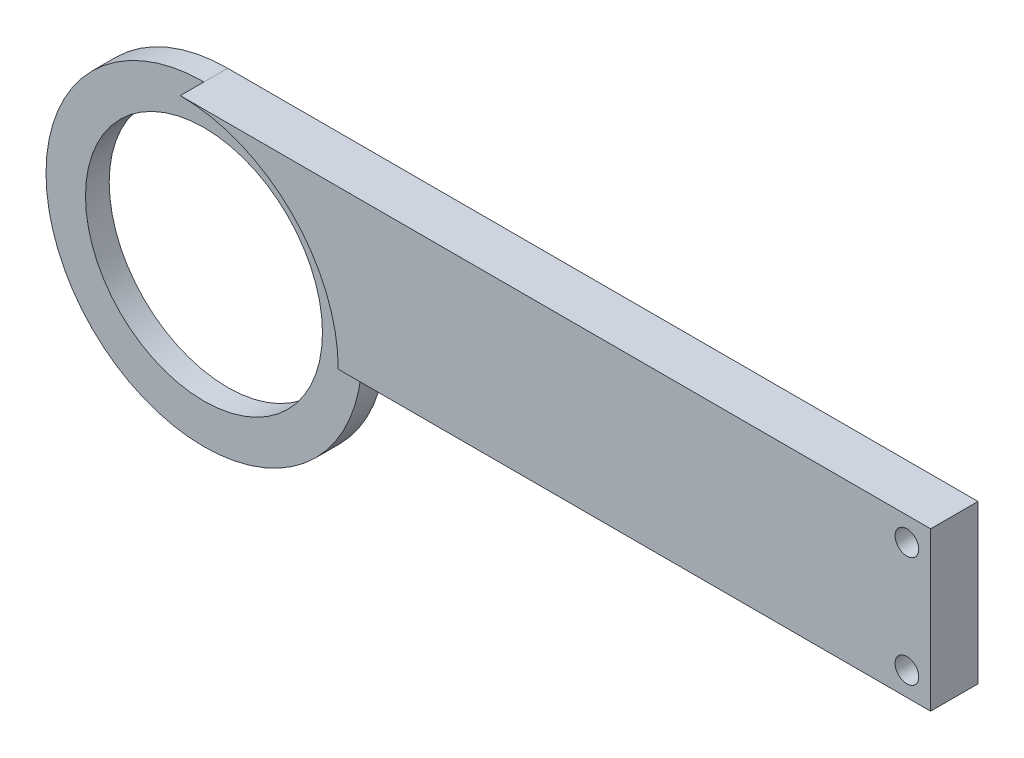
from build123d import *

# Parameters (mm, degrees)
BOSS_EXTRU_1_DEPTH      = 6
ESQUISSE2_R             = 20
ESQUISSE2_R_2           = 15
ENL_V_MAT_EXTRU_1_DEPTH = 3
ESQUISSE3_W             = 9.17
ESQUISSE3_H             = 20
BOSS_EXTRU_2_DEPTH      = 6
ESQUISSE4_R             = 1.5
ENL_V_MAT_EXTRU_2_DEPTH = 10


with BuildPart() as part:
    # Esquisse1 → Boss.-Extru.1 (new body)
    with BuildSketch(Plane.XY):
        with BuildLine():
            Line((42.613906887, 3.786407767), (42.613906887, 23.786407767))
            Line((42.613906887, 23.786407767), (-43.211335831, 23.786407767))
            ThreePointArc((-43.211335831, 23.786407767), (-29.069200208, 17.928543391), (-23.211335831, 3.786407767))
            Line((-23.211335831, 3.786407767), (42.613906887, 3.786407767))
        make_face()
        with BuildLine():
            ThreePointArc((-23.211335831, 3.786407767), (-29.069200208, 17.928543391), (-43.211335831, 23.786407767))
            Line((-43.211335831, 23.786407767), (-43.211335831, 18.786407767))
            ThreePointArc((-43.211335831, 18.786407767), (-32.604734113, 14.393009485), (-28.211335831, 3.786407767))
            Line((-28.211335831, 3.786407767), (-23.211335831, 3.786407767))
        make_face()
        with BuildLine():
            Line((-43.211335831, 18.786407767), (-43.211335831, 23.786407767))
            ThreePointArc((-43.211335831, 23.786407767), (-57.353471455, -10.355727857), (-23.211335831, 3.786407767))
            Line((-23.211335831, 3.786407767), (-28.211335831, 3.786407767))
            ThreePointArc((-28.211335831, 3.786407767), (-53.817937549, -6.820193951), (-43.211335831, 18.786407767))
        make_face()
    extrude(amount=BOSS_EXTRU_1_DEPTH)

    # Esquisse2 → Enlèv. mat.-Extru.1 (cut)
    with BuildSketch(Plane.XY.offset(6)):
        with Locations((-43.211335831, 3.786407767)):
            Circle(ESQUISSE2_R)
        with Locations((-43.211335831, 3.786407767)):
            Circle(ESQUISSE2_R_2, mode=Mode.SUBTRACT)
    extrude(amount=-ENL_V_MAT_EXTRU_1_DEPTH, mode=Mode.SUBTRACT)

    # Esquisse3 → Boss.-Extru.2 (add)
    with BuildSketch(Plane.XY.offset(6)):
        with Locations((47.198906887, 13.786407767)):
            Rectangle(ESQUISSE3_W, ESQUISSE3_H)
    extrude(amount=-BOSS_EXTRU_2_DEPTH)

    # Esquisse4 → Enlèv. mat.-Extru.2 (cut)
    with BuildSketch(Plane(origin=(0, 0, 0), x_dir=(-1, 0, 0), z_dir=(0, 0, -1))):
        with Locations((-48.783906887, 20.786407767)):
            Circle(ESQUISSE4_R)
        with Locations((-48.783906887, 6.786407767)):
            Circle(ESQUISSE4_R)
    extrude(amount=-ENL_V_MAT_EXTRU_2_DEPTH, mode=Mode.SUBTRACT)


solid = part.part
